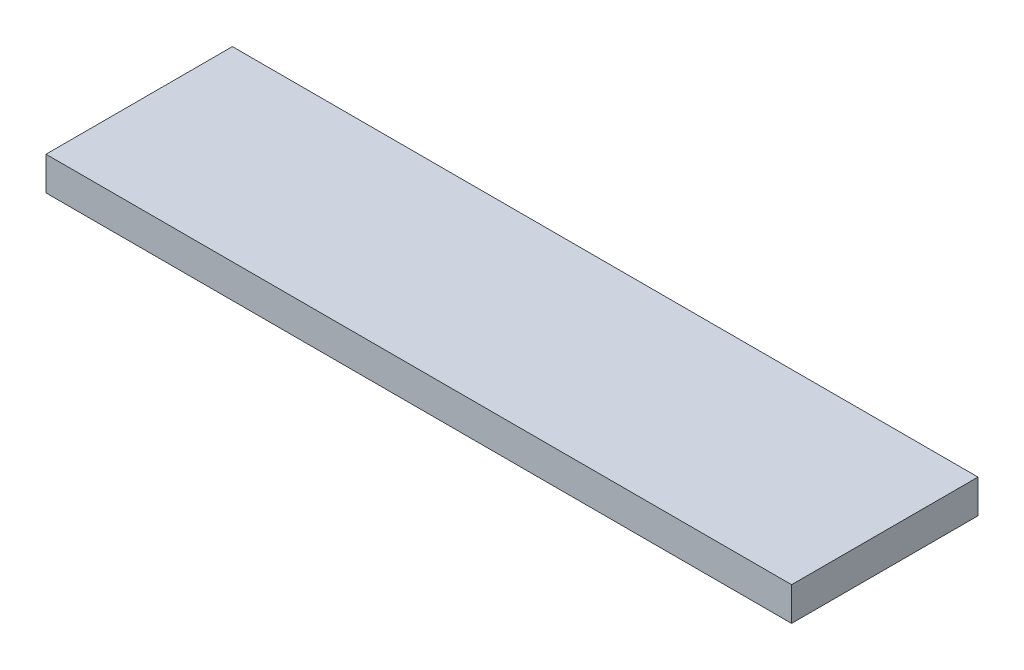
from build123d import *

# Parameters (mm, degrees)
SKETCH1_W           = 400
SKETCH1_H           = 100
BOSS_EXTRUDE1_DEPTH = 18


with BuildPart() as part:
    # Sketch1 → Boss-Extrude1 (new body)
    with BuildSketch(Plane(origin=(0, 0, 0), x_dir=(1, 0, 0), z_dir=(0, 1, 0))):
        with Locations((200, 50)):
            Rectangle(SKETCH1_W, SKETCH1_H)
    extrude(amount=BOSS_EXTRUDE1_DEPTH)


solid = part.part
